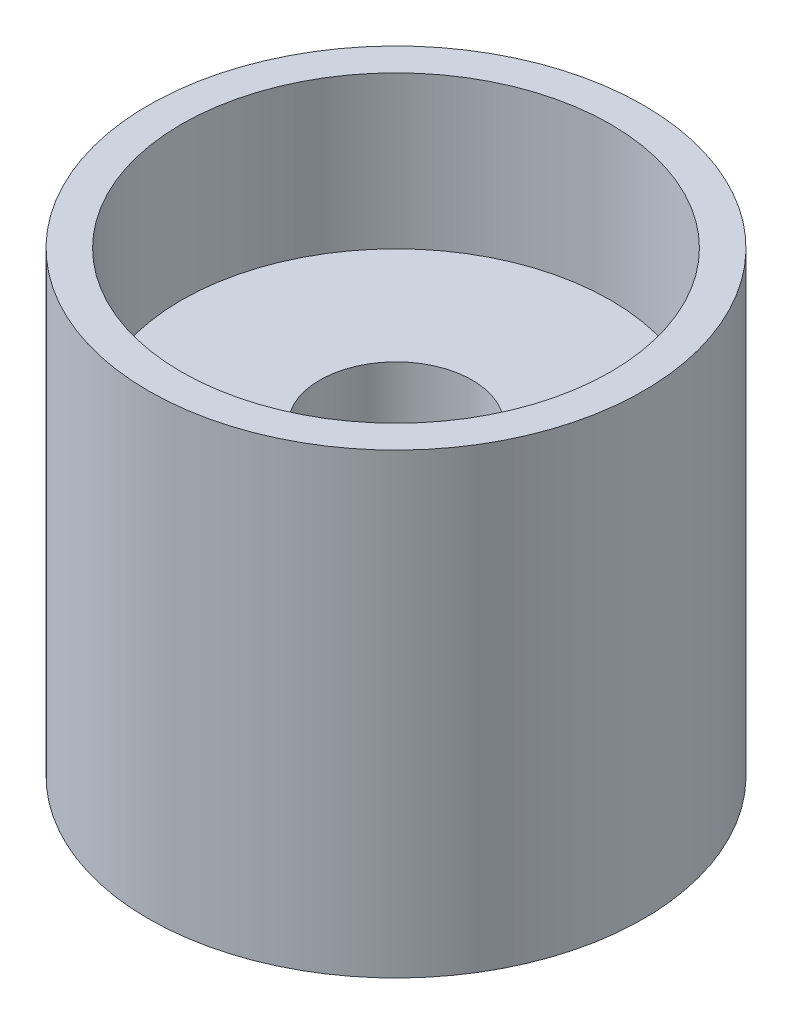
from build123d import *


with BuildPart() as part:
    # Sketch2 → Revolve1 (revolve)
    with BuildSketch(Plane.XY):
        Polygon((-3.175, -6.35), (-8.9408, -6.35), (-8.9408, 0), (-10.3124, 0), (-10.3124, -19.05), (-3.175, -19.05), align=None)
    revolve(axis=Axis((0, 0, 0), (0, -1, 0)))


solid = part.part
